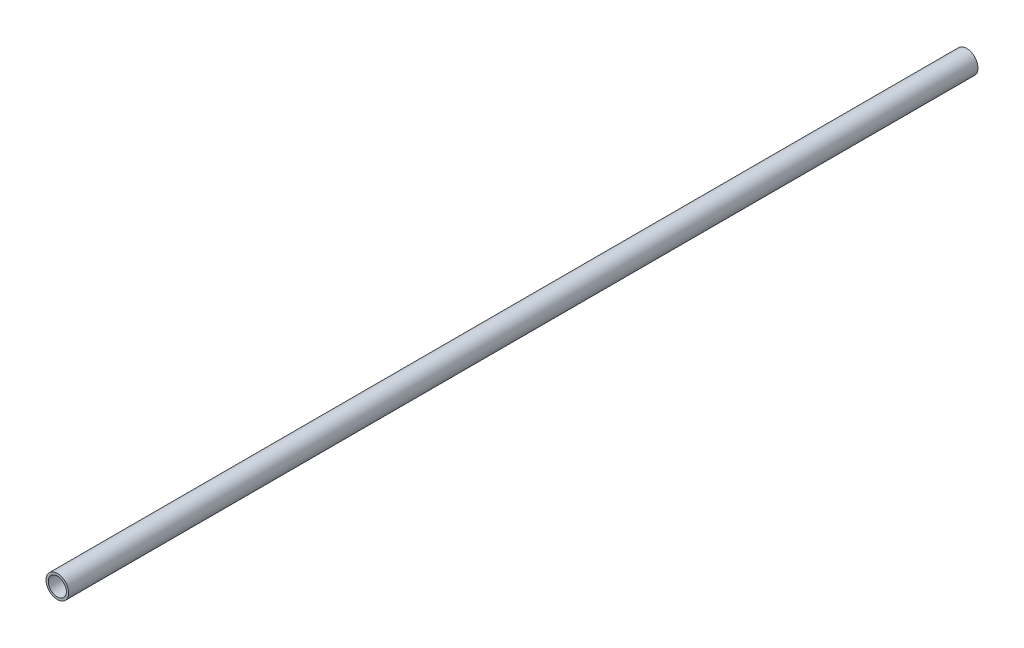
from build123d import *

# Parameters (mm, degrees)
SKETCH1_R           = 10
SKETCH1_R_2         = 8
BOSS_EXTRUDE1_DEPTH = 801.8


with BuildPart() as part:
    # Sketch1 → Boss-Extrude1 (new body)
    with BuildSketch(Plane.XY):
        Circle(SKETCH1_R)
        Circle(SKETCH1_R_2, mode=Mode.SUBTRACT)
    extrude(amount=BOSS_EXTRUDE1_DEPTH)


solid = part.part
